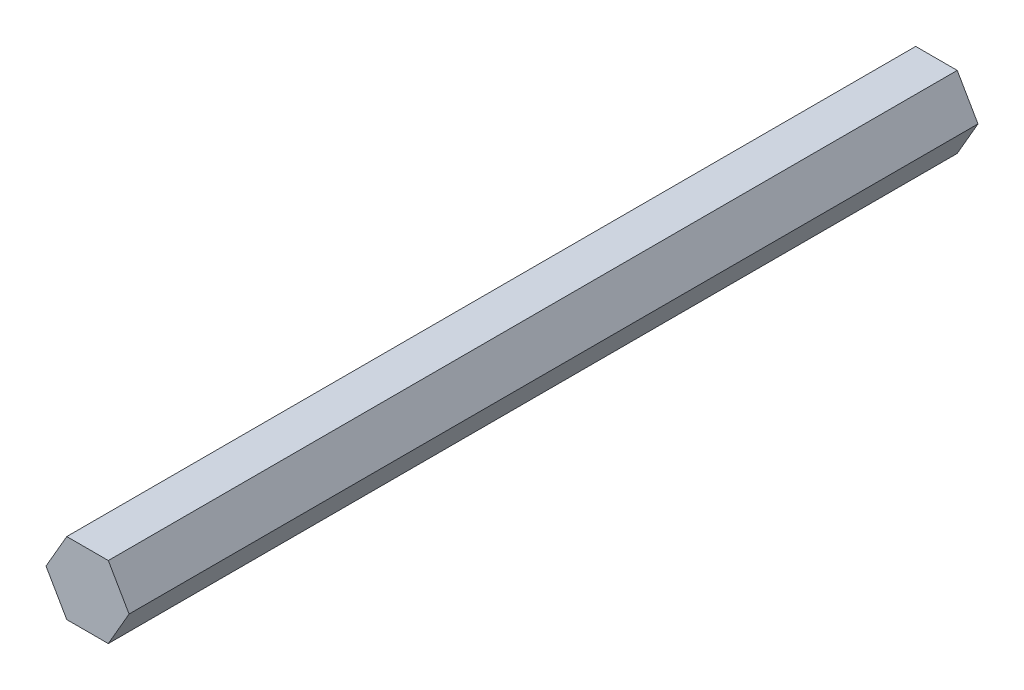
from build123d import *

# Parameters (mm, degrees)
BOSS_EXTRUDE1_DEPTH = 149.86
SKETCH2_R           = 2.54
CUT_EXTRUDE1_DEPTH  = 20.574


with BuildPart() as part:
    # Sketch1 → Boss-Extrude1 (new body)
    with BuildSketch(Plane.XY):
        Polygon((7.332348419, 0), (3.666174209, 6.35), (-3.666174209, 6.35), (-7.332348419, 0), (-3.666174209, -6.35), (3.666174209, -6.35), align=None)
    extrude(amount=BOSS_EXTRUDE1_DEPTH)

    # Sketch2 → Cut-Extrude1 (cut)
    with BuildSketch(Plane(origin=(0, 0, 0), x_dir=(-1, 0, 0), z_dir=(0, 0, -1))):
        Circle(SKETCH2_R)
    extrude(amount=-CUT_EXTRUDE1_DEPTH, mode=Mode.SUBTRACT)


solid = part.part
